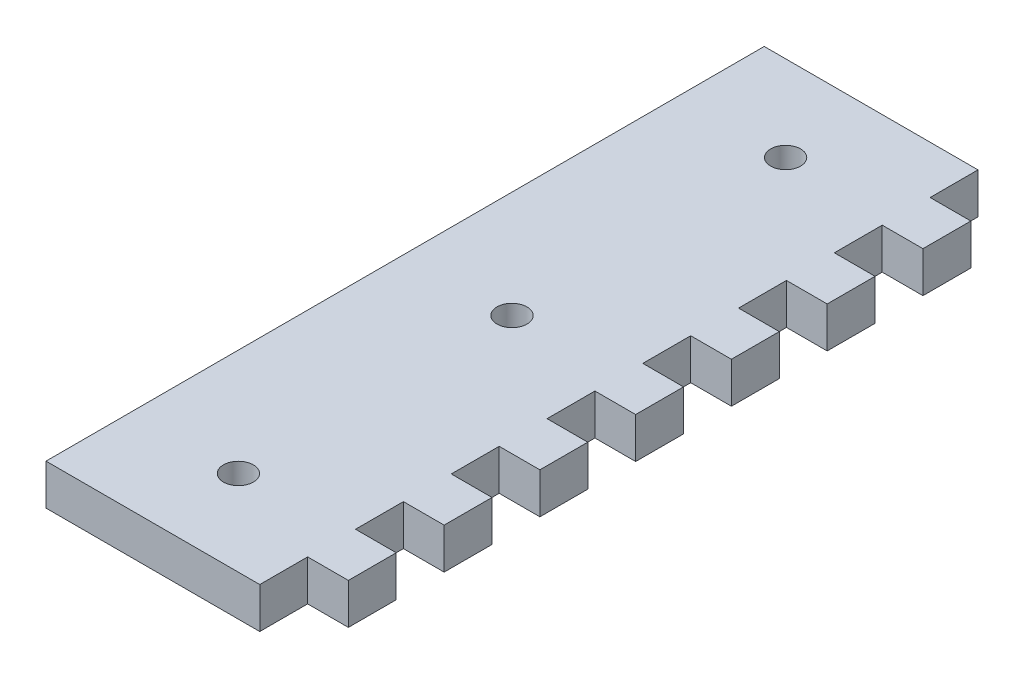
from build123d import *

# Parameters (mm, degrees)
SKETCH1_W           = 25
SKETCH1_H           = 84
SKETCH1_R           = 1.75
SKETCH1_W_2         = 4.7625
SKETCH1_H_2         = 5.6
BOSS_EXTRUDE1_DEPTH = 4.7625


with BuildPart() as part:
    # Sketch1 → Boss-Extrude1 (new body)
    with BuildSketch(Plane(origin=(0, 0, 0), x_dir=(1, 0, 0), z_dir=(0, 1, 0))):
        with Locations((12.5, 42)):
            Rectangle(SKETCH1_W, SKETCH1_H)
        with Locations((12.5, 10)):
            Circle(SKETCH1_R, mode=Mode.SUBTRACT)
        with Locations((12.5, 42)):
            Circle(SKETCH1_R, mode=Mode.SUBTRACT)
        with Locations((12.5, 74)):
            Circle(SKETCH1_R, mode=Mode.SUBTRACT)
        with Locations((27.38125, 30.8)):
            Rectangle(SKETCH1_W_2, SKETCH1_H_2)
        with Locations((27.38125, 19.6)):
            Rectangle(SKETCH1_W_2, SKETCH1_H_2)
        with Locations((27.38125, 42)):
            Rectangle(SKETCH1_W_2, SKETCH1_H_2)
        with Locations((27.38125, 53.2)):
            Rectangle(SKETCH1_W_2, SKETCH1_H_2)
        with Locations((27.38125, 64.4)):
            Rectangle(SKETCH1_W_2, SKETCH1_H_2)
        with Locations((27.38125, 75.6)):
            Rectangle(SKETCH1_W_2, SKETCH1_H_2)
        with Locations((27.38125, 8.4)):
            Rectangle(SKETCH1_W_2, SKETCH1_H_2)
    extrude(amount=BOSS_EXTRUDE1_DEPTH)


solid = part.part
